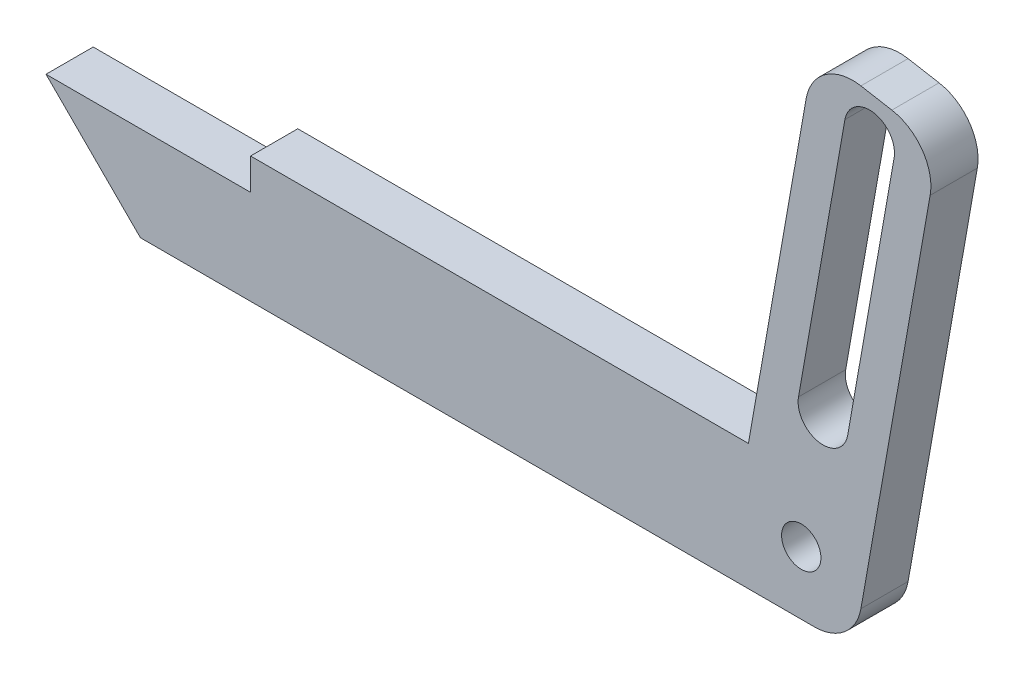
from build123d import *

# Parameters (mm, degrees)
BOSS_EXTRUDE1_DEPTH = 3
SKETCH2_R           = 1.25
CUT_EXTRUDE1_DEPTH  = 3
FILLET1_R           = 3


with BuildPart() as part:
    # Sketch1 → Boss-Extrude1 (new body)
    with BuildSketch(Plane.XY):
        Polygon((-56.024750416, -23.482321131), (-9.384750416, -23.482321131), (-5.192883407, 0.290938026), (2.685578617, -1.098247395), (-2.671953367, -31.482321131), (-48.024750416, -31.482321131), align=None)
    extrude(amount=BOSS_EXTRUDE1_DEPTH)

    # Sketch2 → Cut-Extrude1 (cut)
    with BuildSketch(Plane.XY.offset(3)):
        with Locations((-6.028351891, -27.482321131)):
            Circle(SKETCH2_R)
        Polygon((-56.024750416, -23.482321131), (-41.024750416, -23.482321131), (-41.024750416, -25.482321131), (-54.024750416, -25.482321131), align=None)
        with BuildLine():
            Line((-3.251155147, -2.590007585), (-6.203174167, -19.331739386))
            ThreePointArc((-6.203174167, -19.331739386), (-4.915458342, -21.170788176), (-3.076409552, -19.88307235))
            Line((-3.076409552, -19.88307235), (-0.124390531, -3.141340549))
            ThreePointArc((-0.124390531, -3.141340549), (-1.412106357, -1.302291759), (-3.251155147, -2.590007585))
        make_face()
    extrude(amount=-CUT_EXTRUDE1_DEPTH, mode=Mode.SUBTRACT)

    # Fillet1
    fillet1_edges = [part.edges().sort_by_distance(p)[0] for p in [
        (-5.192883407, 0.290938026, 1.5),
        (2.685578617, -1.098247395, 1.5),
        (-2.671953367, -31.482321131, 1.5),
    ]]
    fillet(fillet1_edges, radius=FILLET1_R)


solid = part.part
